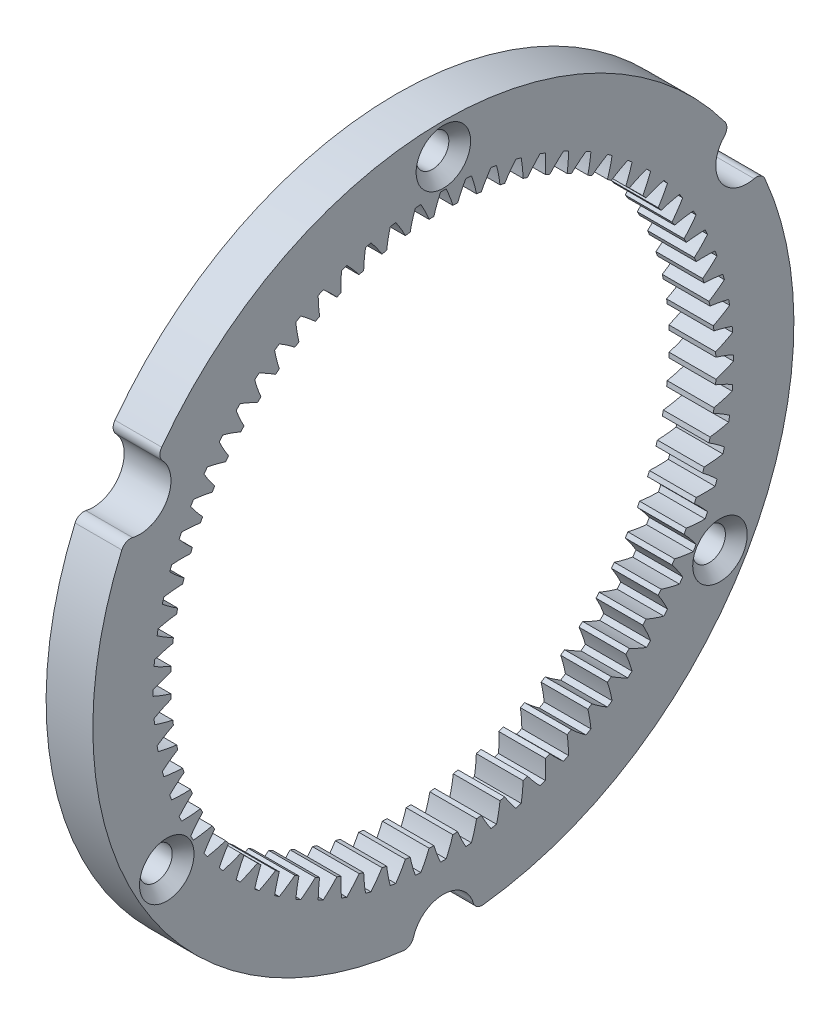
from build123d import *

# Parameters (mm, degrees)
BASPROSKE_W        = 3
BASPROSKE_H        = 5
TOOTHCUT_DEPTH     = 32.960913629
TEETHCUTS_COUNT    = 72
TEETHCUTS_ANGLE    = 355
SKETCH2_R          = 1.05
CUT_EXTRUDE2_DEPTH = 10
SKETCH3_R          = 2
CUT_EXTRUDE3_DEPTH = 10
FILLET1_R          = 0.6
CHAMFER1_SIZE      = 0.7


with BuildPart() as part:
    # BasProSke → Base-Revolve (revolve)
    with BuildSketch(Plane(origin=(0, 0, 0), x_dir=(1, 0, 0), z_dir=(0, 1, 0))):
        with Locations((1.5, 20)):
            Rectangle(BASPROSKE_W, BASPROSKE_H)
    revolve(axis=Axis((-10, 0, 0), (1, 0, 0)))

    # TooCutSke → ToothCut (cut, through all)
    with BuildSketch(Plane(origin=(0, 0, 0), x_dir=(0, 0, -1), z_dir=(1, 0, 0))):
        with BuildLine():
            ThreePointArc((0.616898898, 17.463707536), (0.418864032, 18.051939155), (0.180757644, 18.62512289))
            ThreePointArc((0.180757644, 18.62512289), (0, 18.626), (-0.180757644, 18.62512289))
            ThreePointArc((-0.180757644, 18.62512289), (-0.418864032, 18.051939155), (-0.616898898, 17.463707536))
            ThreePointArc((-0.616898898, 17.463707536), (0, 17.4746), (0.616898898, 17.463707536))
        make_face()
    toothcut = extrude(amount=TOOTHCUT_DEPTH, mode=Mode.SUBTRACT)

    # TeethCuts: ToothCut ×72 about axis
    teethcuts_axis = Axis((-10, 0, 0), (1, 0, 0))
    for i in range(1, TEETHCUTS_COUNT):
        add(toothcut.rotate(teethcuts_axis, i * TEETHCUTS_ANGLE / (TEETHCUTS_COUNT - 1)), mode=Mode.SUBTRACT)

    # Sketch2 → Cut-Extrude2 (cut)
    with BuildSketch(Plane(origin=(3, 0, 0), x_dir=(0, 0, -1), z_dir=(1, 0, 0))):
        with Locations((0, 20.5)):
            Circle(SKETCH2_R)
        with Locations((17.753520778, -10.25)):
            Circle(SKETCH2_R)
        with Locations((-17.753520778, -10.25)):
            Circle(SKETCH2_R)
    extrude(amount=-CUT_EXTRUDE2_DEPTH, mode=Mode.SUBTRACT)

    # Sketch3 → Cut-Extrude3 (cut)
    with BuildSketch(Plane(origin=(3, 0, 0), x_dir=(0, 0, -1), z_dir=(1, 0, 0))):
        with Locations((19.485571585, 11.25)):
            Circle(SKETCH3_R)
        with Locations((0, -22.5)):
            Circle(SKETCH3_R)
        with Locations((-19.485571585, 11.25)):
            Circle(SKETCH3_R)
    extrude(amount=-CUT_EXTRUDE3_DEPTH, mode=Mode.SUBTRACT)

    # Fillet1
    fillet1_edges = [part.edges().sort_by_distance(p)[0] for p in [
        (1.5, 9.475216261, 20.407603407),
        (1.5, 12.93589485, 18.409579692),
        (1.5, 9.475216261, -20.407603407),
        (1.5, -22.411111111, -1.998023715),
        (1.5, -22.411111111, 1.998023715),
        (1.5, 12.93589485, -18.409579692),
    ]]
    fillet(fillet1_edges, radius=FILLET1_R)

    # Chamfer1
    chamfer1_edges = [part.edges().sort_by_distance(p)[0] for p in [
        (3, -10.25, -16.703520778),
        (3, -10.25, 18.803520778),
        (3, 20.5, 1.05),
    ]]
    chamfer(chamfer1_edges, length=CHAMFER1_SIZE)


solid = part.part
